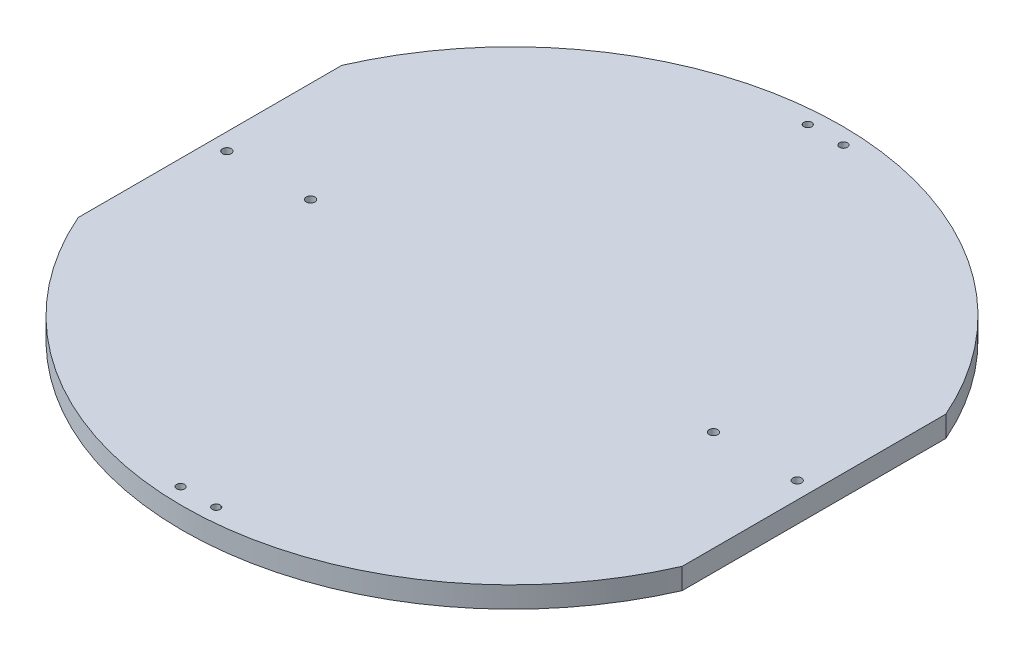
from build123d import *

# Parameters (mm, degrees)
CROQUIS1_R              = 1.65
CROQUIS1_R_2            = 1.5
SALIENTE_EXTRUIR1_DEPTH = 8


with BuildPart() as part:
    # Croquis1 → Saliente-Extruir1 (new body)
    with BuildSketch(Plane(origin=(0, 0, 0), x_dir=(1, 0, 0), z_dir=(0, 1, 0))):
        with BuildLine():
            Line((-114.564392374, -50), (-114.564392374, 50))
            ThreePointArc((-114.564392374, 50), (0, 125), (114.564392374, 50))
            Line((114.564392374, 50), (114.564392374, -50))
            ThreePointArc((114.564392374, -50), (0, -125), (-114.564392374, -50))
        make_face()
        with Locations((108.164392374, 0)):
            Circle(CROQUIS1_R, mode=Mode.SUBTRACT)
        with Locations((76.414392374, 0)):
            Circle(CROQUIS1_R, mode=Mode.SUBTRACT)
        with Locations((-108.164392374, 0)):
            Circle(CROQUIS1_R, mode=Mode.SUBTRACT)
        with Locations((-76.414392374, 0)):
            Circle(CROQUIS1_R, mode=Mode.SUBTRACT)
        with Locations((-6.75, 118.95)):
            Circle(CROQUIS1_R_2, mode=Mode.SUBTRACT)
        with Locations((6.75, 118.95)):
            Circle(CROQUIS1_R_2, mode=Mode.SUBTRACT)
        with Locations((6.75, -118.95)):
            Circle(CROQUIS1_R_2, mode=Mode.SUBTRACT)
        with Locations((-6.75, -118.95)):
            Circle(CROQUIS1_R_2, mode=Mode.SUBTRACT)
    extrude(amount=SALIENTE_EXTRUIR1_DEPTH)


solid = part.part
